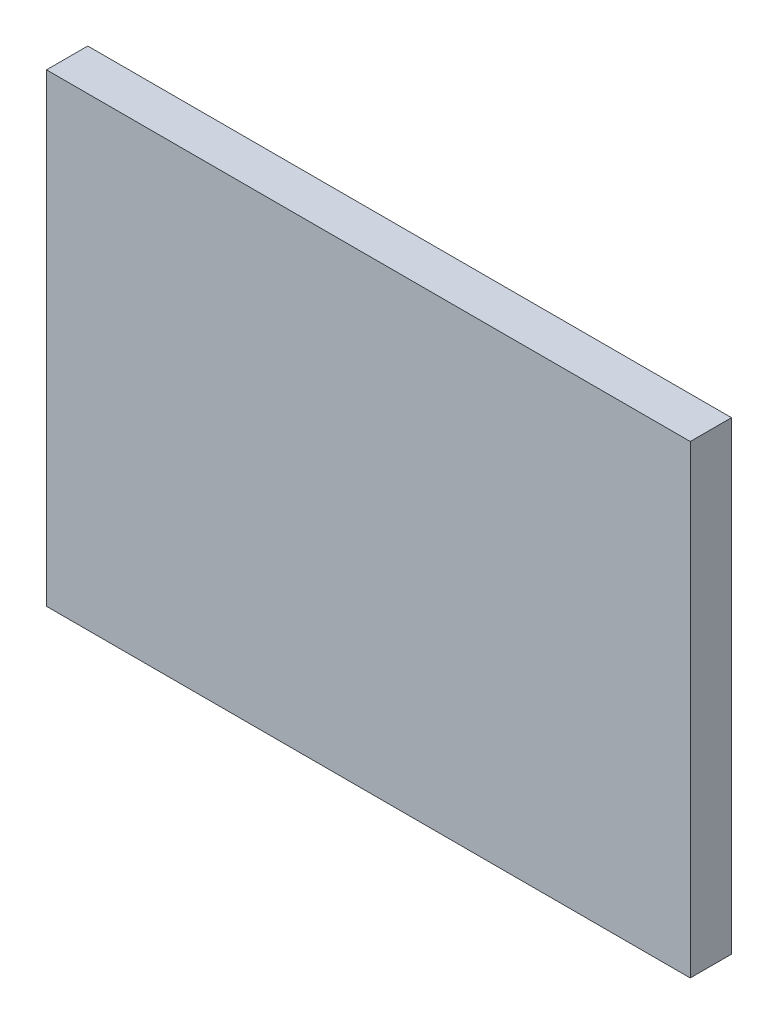
from build123d import *

# Parameters (mm, degrees)
SKETCH1_W           = 59.3
SKETCH1_H           = 42.8
BOSS_EXTRUDE1_DEPTH = 3.8


with BuildPart() as part:
    # Sketch1 → Boss-Extrude1 (new body)
    with BuildSketch(Plane.XY):
        Rectangle(SKETCH1_W, SKETCH1_H)
    extrude(amount=BOSS_EXTRUDE1_DEPTH)


solid = part.part
